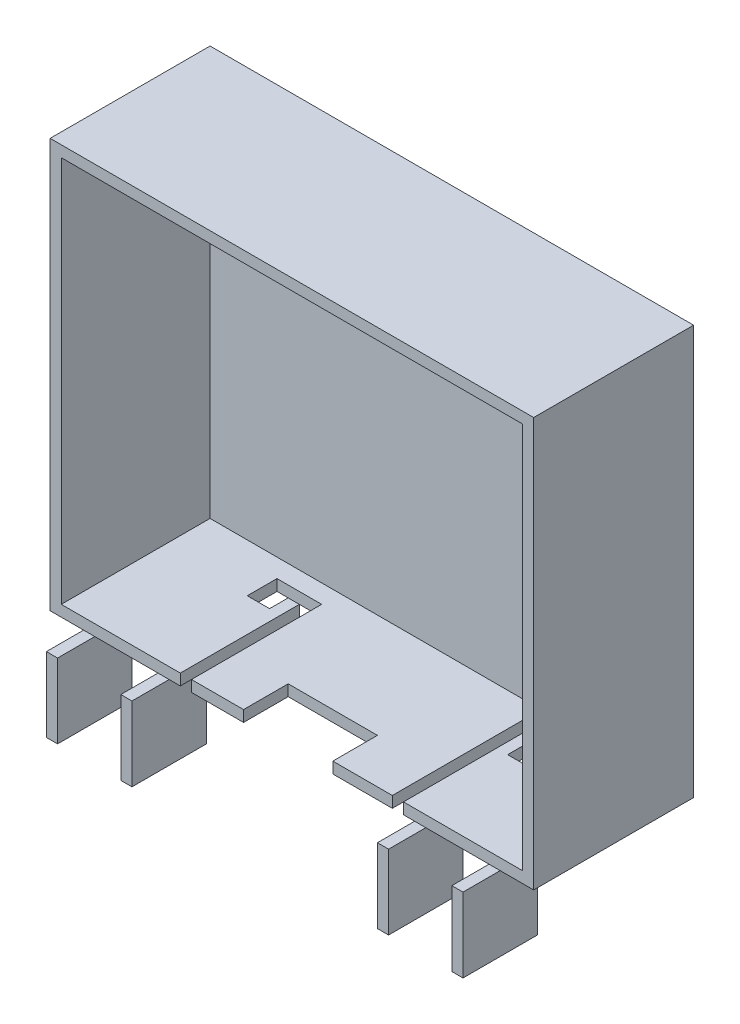
from build123d import *

# Parameters (mm, degrees)
SKETCH_1_W          = 65
SKETCH_1_H          = 55
EXTRUDE_1_DEPTH     = 1.5
SKETCH_2_W          = 65
SKETCH_2_H          = 55
SKETCH_2_W_2        = 62
SKETCH_2_H_2        = 52
EXTRUDE_2_DEPTH     = 20
SKETCH_3_W          = 12
SKETCH_3_H          = 6
CUT_EXTRUDE_1_DEPTH = 1.5
CUT_EXTRUDE_2_DEPTH = 1.5
SKETCH_5_W          = 1.5
SKETCH_5_H          = 10
EXTRUDE_3_DEPTH     = 10


with BuildPart() as part:
    # 草图1 → 凸台-拉伸1 (new body)
    with BuildSketch(Plane.XY):
        with Locations((32.5, -27.5)):
            Rectangle(SKETCH_1_W, SKETCH_1_H)
    extrude(amount=EXTRUDE_1_DEPTH)

    # 草图2 → 凸台-拉伸2 (add)
    with BuildSketch(Plane.XY.offset(1.5)):
        with Locations((32.5, -27.5)):
            Rectangle(SKETCH_2_W, SKETCH_2_H)
        with Locations((32.5, -27.5)):
            Rectangle(SKETCH_2_W_2, SKETCH_2_H_2, mode=Mode.SUBTRACT)
    extrude(amount=EXTRUDE_2_DEPTH)

    # 草图3 → 切除-拉伸1 (cut)
    with BuildSketch(Plane.XZ.offset(55)):
        with Locations((32, 18.5)):
            Rectangle(SKETCH_3_W, SKETCH_3_H)
    extrude(amount=-CUT_EXTRUDE_1_DEPTH, mode=Mode.SUBTRACT)

    # 草图4 → 切除-拉伸2 (cut)
    with BuildSketch(Plane.XZ.offset(55)):
        Polygon((19, 21.5), (17.5, 21.5), (17.5, 5.5), (16, 5.5), (16, 8), (13, 8), (13, 4), (19, 4), align=None)
        Polygon((47.5, 5.5), (47.5, 21.5), (46, 21.5), (46, 4), (52, 4), (52, 9), (49, 9), (49, 5.5), align=None)
    extrude(amount=-CUT_EXTRUDE_2_DEPTH, mode=Mode.SUBTRACT)

    # 草图5 → 凸台-拉伸3 (add)
    with BuildSketch(Plane.XZ.offset(55)):
        with Locations((15.25, 21.5)):
            Rectangle(SKETCH_5_W, SKETCH_5_H)
        with Locations((5.25, 21.5)):
            Rectangle(SKETCH_5_W, SKETCH_5_H)
        with Locations((49.75, 21.5)):
            Rectangle(SKETCH_5_W, SKETCH_5_H)
        with Locations((59.75, 21.5)):
            Rectangle(SKETCH_5_W, SKETCH_5_H)
    extrude(amount=EXTRUDE_3_DEPTH)


solid = part.part
